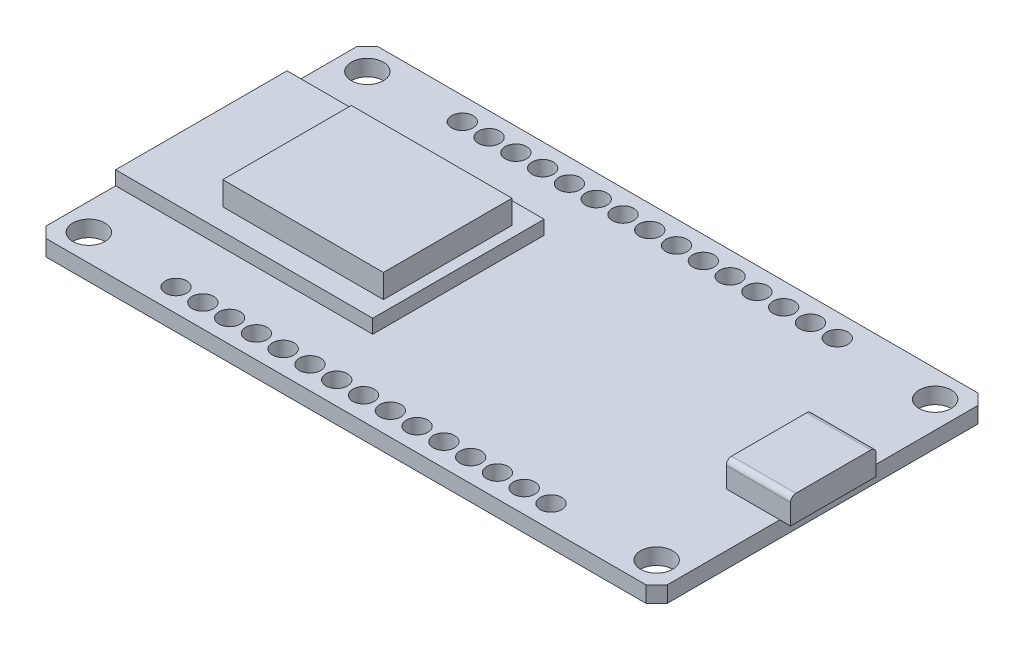
from build123d import *

# Parameters (mm, degrees)
SKETCH1_R           = 1.5
BOSS_EXTRUDE1_DEPTH = 1.5
SKETCH2_W           = 24
SKETCH2_H           = 16
BOSS_EXTRUDE2_DEPTH = 1.3
SKETCH3_W           = 15
SKETCH3_H           = 12
BOSS_EXTRUDE3_DEPTH = 2.2
SKETCH4_R           = 1
CUT_EXTRUDE1_DEPTH  = 2.5
SKETCH5_W           = 6
SKETCH5_H           = 8
BOSS_EXTRUDE4_DEPTH = 2.4
FILLET1_R           = 0.5


with BuildPart() as part:
    # Sketch1 → Boss-Extrude1 (new body)
    with BuildSketch(Plane(origin=(0, 0, 0), x_dir=(1, 0, 0), z_dir=(0, 1, 0))):
        Polygon((0, 30), (1, 31), (57, 31), (58, 30), (58, 1), (57, 0), (1, 0), (0, 1), align=None)
        with Locations((2.5, 28.5)):
            Circle(SKETCH1_R, mode=Mode.SUBTRACT)
        with Locations((2.5, 2.5)):
            Circle(SKETCH1_R, mode=Mode.SUBTRACT)
        with Locations((55.5, 28.5)):
            Circle(SKETCH1_R, mode=Mode.SUBTRACT)
        with Locations((55.5, 2.5)):
            Circle(SKETCH1_R, mode=Mode.SUBTRACT)
    extrude(amount=BOSS_EXTRUDE1_DEPTH)

    # Sketch2 → Boss-Extrude2 (add)
    with BuildSketch(Plane(origin=(0, 1.5, 0), x_dir=(1, 0, 0), z_dir=(0, 1, 0))):
        with Locations((12, 15.5)):
            Rectangle(SKETCH2_W, SKETCH2_H)
    extrude(amount=BOSS_EXTRUDE2_DEPTH)

    # Sketch3 → Boss-Extrude3 (add)
    with BuildSketch(Plane(origin=(0, 2.8, 0), x_dir=(1, 0, 0), z_dir=(0, 1, 0))):
        with Locations((15.5, 15.5)):
            Rectangle(SKETCH3_W, SKETCH3_H)
    extrude(amount=BOSS_EXTRUDE3_DEPTH)

    # Sketch4 → Cut-Extrude1 (cut, through all)
    with BuildSketch(Plane(origin=(0, 1.5, 0), x_dir=(1, 0, 0), z_dir=(0, 1, 0))):
        with Locations((11, 2.139657304)):
            Circle(SKETCH4_R)
        with Locations((13.5, 2.139657304)):
            Circle(SKETCH4_R)
        with Locations((16, 2.139657304)):
            Circle(SKETCH4_R)
        with Locations((18.5, 2.139657304)):
            Circle(SKETCH4_R)
        with Locations((21, 2.139657304)):
            Circle(SKETCH4_R)
        with Locations((23.5, 2.139657304)):
            Circle(SKETCH4_R)
        with Locations((26, 2.139657304)):
            Circle(SKETCH4_R)
        with Locations((28.5, 2.139657304)):
            Circle(SKETCH4_R)
        with Locations((31, 2.139657304)):
            Circle(SKETCH4_R)
        with Locations((33.5, 2.139657304)):
            Circle(SKETCH4_R)
        with Locations((36, 2.139657304)):
            Circle(SKETCH4_R)
        with Locations((38.5, 2.139657304)):
            Circle(SKETCH4_R)
        with Locations((41, 2.139657304)):
            Circle(SKETCH4_R)
        with Locations((43.5, 2.139657304)):
            Circle(SKETCH4_R)
        with Locations((46, 2.139657304)):
            Circle(SKETCH4_R)
        with Locations((46, 28.860342696)):
            Circle(SKETCH4_R)
        with Locations((43.5, 28.860342696)):
            Circle(SKETCH4_R)
        with Locations((41, 28.860342696)):
            Circle(SKETCH4_R)
        with Locations((38.5, 28.860342696)):
            Circle(SKETCH4_R)
        with Locations((36, 28.860342696)):
            Circle(SKETCH4_R)
        with Locations((33.5, 28.860342696)):
            Circle(SKETCH4_R)
        with Locations((31, 28.860342696)):
            Circle(SKETCH4_R)
        with Locations((28.5, 28.860342696)):
            Circle(SKETCH4_R)
        with Locations((26, 28.860342696)):
            Circle(SKETCH4_R)
        with Locations((23.5, 28.860342696)):
            Circle(SKETCH4_R)
        with Locations((21, 28.860342696)):
            Circle(SKETCH4_R)
        with Locations((18.5, 28.860342696)):
            Circle(SKETCH4_R)
        with Locations((16, 28.860342696)):
            Circle(SKETCH4_R)
        with Locations((13.5, 28.860342696)):
            Circle(SKETCH4_R)
        with Locations((11, 28.860342696)):
            Circle(SKETCH4_R)
    extrude(amount=-CUT_EXTRUDE1_DEPTH, mode=Mode.SUBTRACT)

    # Sketch5 → Boss-Extrude4 (add)
    with BuildSketch(Plane(origin=(0, 1.5, 0), x_dir=(1, 0, 0), z_dir=(0, 1, 0))):
        with Locations((56, 15.5)):
            Rectangle(SKETCH5_W, SKETCH5_H)
    extrude(amount=BOSS_EXTRUDE4_DEPTH)

    # Fillet1
    fillet1_edges = [part.edges().sort_by_distance(p)[0] for p in [
        (56, 3.9, -11.5),
        (56, 3.9, -19.5),
    ]]
    fillet(fillet1_edges, radius=FILLET1_R)


solid = part.part
